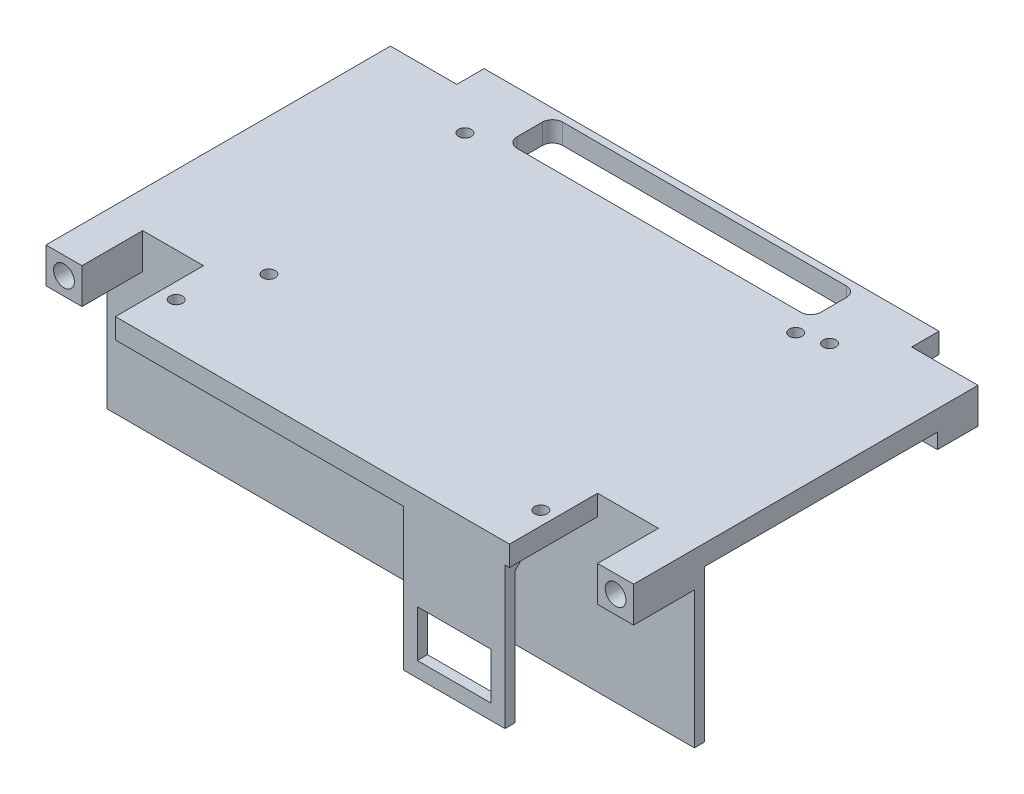
from build123d import *

# Parameters (mm, degrees)
BOSS_EXTRUDE1_DEPTH             = 4
SKETCH3_W                       = 7.1
SKETCH3_H                       = 8
BOSS_EXTRUDE3_DEPTH             = 3
SKETCH4_R                       = 2.05
CUT_EXTRUDE1_DEPTH              = 7
MIRROR2_COPY_1_SKETCH_W         = 7.1
MIRROR2_COPY_1_SKETCH_H         = 8
MIRROR2_COPY_1_DEPTH            = 3
MIRROR2_COPY_2_SKETCH_R         = 2.05
MIRROR2_COPY_2_DEPTH            = 7
SKETCH5_W                       = 60
SKETCH5_H                       = 9
CUT_EXTRUDE2_DEPTH              = 72.37226352
FILLET1_R                       = 2
SKETCH7_W                       = 101.8
SKETCH7_H                       = 1
CUT_EXTRUDE3_DEPTH              = 72.37226352
SKETCH8_W                       = 116
SKETCH8_H                       = 2
BOSS_EXTRUDE4_DEPTH             = 30
SKETCH9_W                       = 12
SKETCH9_H                       = 18
CUT_EXTRUDE4_DEPTH              = 10
SKETCH10_W                      = 7.1
SKETCH10_H                      = 4
BOSS_EXTRUDE5_DEPTH             = 3
SKETCH12_W                      = 1.5
SKETCH12_H                      = 4
BOSS_EXTRUDE6_DEPTH             = 2
SKETCH13_W                      = 36
SKETCH13_H                      = 2
BOSS_EXTRUDE7_DEPTH             = 30
SKETCH14_W                      = 1.5
SKETCH14_H                      = 4
BOSS_EXTRUDE8_DEPTH             = 1
BOSS_EXTRUDE9_REACH             = 79.055
BOSS_EXTRUDE9_DIRECTION_2_REACH = 79.055
SKETCH16_W                      = 20
SKETCH16_H                      = 28
SKETCH16_W_2                    = 14.6
SKETCH16_H_2                    = 9.2
BOSS_EXTRUDE10_DEPTH            = 2.6
SKETCH17_W                      = 12
SKETCH17_H                      = 18
CUT_EXTRUDE5_DEPTH              = 78.054785705
SKETCH18_W                      = 6
SKETCH18_H                      = 6
CUT_EXTRUDE6_DEPTH              = 79.759380394
SKETCH22_R                      = 1.25
CUT_EXTRUDE7_DEPTH              = 4
SKETCH25_W                      = 6
SKETCH25_H                      = 30
CUT_EXTRUDE11_DEPTH             = 10
SKETCH26_W                      = 5.701552738
SKETCH26_H                      = 30.562488548
SKETCH26_W_2                    = 6.53419365
SKETCH26_H_2                    = 28.524331859
CUT_EXTRUDE12_DEPTH             = 78.810282097
CUT_EXTRUDE12_DEPTH_BACK        = 78.810282097
SKETCH27_R                      = 1.25
CUT_EXTRUDE13_DEPTH             = 79.230428862
SKETCH28_W                      = 89.8
SKETCH28_H                      = 0.6
SKETCH28_W_2                    = 77.8
CUT_EXTRUDE14_DEPTH             = 79.230428862
CHAMFER1_SIZE                   = 2


with BuildPart() as part:
    # Sketch1 → Boss-Extrude1 (new body)
    with BuildSketch(Plane(origin=(0, 0, 0), x_dir=(1, 0, 0), z_dir=(0, 1, 0))):
        Polygon((-58, -34), (-50.9, -34), (-50.9, -41), (50.9, -41), (50.9, -34), (58, -34), (58, 34), (50.9, 34), (50.9, 41), (-50.9, 41), (-50.9, 34), (-58, 34), align=None)
    extrude(amount=BOSS_EXTRUDE1_DEPTH)

    # Sketch3 → Boss-Extrude3 (add)
    with BuildSketch(Plane.XZ):
        with Locations((-54.45, -30)):
            Rectangle(SKETCH3_W, SKETCH3_H)
    boss_extrude3 = extrude(amount=BOSS_EXTRUDE3_DEPTH)

    # Sketch4 → Cut-Extrude1 (cut)
    with BuildSketch(Plane(origin=(0, 0, -34), x_dir=(-1, 0, 0), z_dir=(0, 0, -1))):
        with Locations((54.45, 0.5)):
            Circle(SKETCH4_R)
    cut_extrude1 = extrude(amount=-CUT_EXTRUDE1_DEPTH, mode=Mode.SUBTRACT)

    # Mirror1: Boss-Extrude3, Cut-Extrude1 across plane
    add(boss_extrude3.mirror(Plane(origin=(0, 0, 0), x_dir=(0, 0, 1), z_dir=(1, 0, 0))))
    add(cut_extrude1.mirror(Plane(origin=(0, 0, 0), x_dir=(0, 0, 1), z_dir=(1, 0, 0))), mode=Mode.SUBTRACT)

    # Mirror2: Boss-Extrude3, Cut-Extrude1 across plane
    add(boss_extrude3.mirror(Plane.XY))
    add(cut_extrude1.mirror(Plane.XY), mode=Mode.SUBTRACT)

    # Mirror2 copy 1 sketch → Mirror2 copy 1 (add)
    with BuildSketch(Plane(origin=(0, 0, 0), x_dir=(-1, 0, 0), z_dir=(0, -1, 0))):
        with Locations((-54.45, -30)):
            Rectangle(MIRROR2_COPY_1_SKETCH_W, MIRROR2_COPY_1_SKETCH_H)
    extrude(amount=MIRROR2_COPY_1_DEPTH)

    # Mirror2 copy 2 sketch → Mirror2 copy 2 (cut)
    with BuildSketch(Plane.XY.offset(34)):
        with Locations((54.45, 0.5)):
            Circle(MIRROR2_COPY_2_SKETCH_R)
    extrude(amount=-MIRROR2_COPY_2_DEPTH, mode=Mode.SUBTRACT)

    # Sketch5 → Cut-Extrude2 (cut, through all)
    with BuildSketch(Plane(origin=(0, 4, 0), x_dir=(1, 0, 0), z_dir=(0, 1, 0))):
        with Locations((0, 33.5)):
            Rectangle(SKETCH5_W, SKETCH5_H)
    extrude(amount=-CUT_EXTRUDE2_DEPTH, mode=Mode.SUBTRACT)

    # Fillet1
    fillet1_edges = [part.edges().sort_by_distance(p)[0] for p in [
        (-30, 2, -29),
        (-30, 2, -38),
        (30, 2, -38),
        (30, 2, -29),
    ]]
    fillet(fillet1_edges, radius=FILLET1_R)

    # Sketch7 → Cut-Extrude3 (cut, through all)
    with BuildSketch(Plane(origin=(0, 4, 0), x_dir=(1, 0, 0), z_dir=(0, 1, 0))):
        with Locations((0, 40.5)):
            Rectangle(SKETCH7_W, SKETCH7_H)
        with Locations((0, -40.5)):
            Rectangle(SKETCH7_W, SKETCH7_H)
    extrude(amount=-CUT_EXTRUDE3_DEPTH, mode=Mode.SUBTRACT)

    # Sketch8 → Boss-Extrude4 (add)
    with BuildSketch(Plane.XZ):
        with Locations((0, 21)):
            Rectangle(SKETCH8_W, SKETCH8_H)
    extrude(amount=BOSS_EXTRUDE4_DEPTH)

    # Sketch9 → Cut-Extrude4 (cut)
    with BuildSketch(Plane(origin=(0, 4, 0), x_dir=(1, 0, 0), z_dir=(0, 1, 0))):
        with Locations((-44.9, -31)):
            Rectangle(SKETCH9_W, SKETCH9_H)
    extrude(amount=-CUT_EXTRUDE4_DEPTH, mode=Mode.SUBTRACT)

    # Sketch10 → Boss-Extrude5 (add)
    with BuildSketch(Plane.XZ.offset(3)):
        with Locations((-54.45, 24)):
            Rectangle(SKETCH10_W, SKETCH10_H)
        with Locations((54.45, 24)):
            Rectangle(SKETCH10_W, SKETCH10_H)
    extrude(amount=-BOSS_EXTRUDE5_DEPTH)

    # Sketch12 → Boss-Extrude6 (add)
    with BuildSketch(Plane.ZY.offset(51)):
        Polygon((22, -5.8), (22, -16.2), (24.7, -13.5), (24.7, -8.5), align=None)
        with Locations((23.35, -11)):
            Rectangle(SKETCH12_W, SKETCH12_H, mode=Mode.SUBTRACT)
        Polygon((22, -20.8), (22, -31.2), (24.7, -28.5), (24.7, -23.5), align=None)
        with Locations((23.35, -26)):
            Rectangle(SKETCH12_W, SKETCH12_H, mode=Mode.SUBTRACT)
    boss_extrude6 = extrude(amount=-BOSS_EXTRUDE6_DEPTH)

    # Mirror3: Boss-Extrude6 across plane
    add(boss_extrude6.mirror(Plane(origin=(-44.9, 0, 0), x_dir=(0, 0, 1), z_dir=(1, 0, 0))))

    # Sketch13 → Boss-Extrude7 (add)
    with BuildSketch(Plane.XZ):
        with Locations((0, -20.5)):
            Rectangle(SKETCH13_W, SKETCH13_H)
    extrude(amount=BOSS_EXTRUDE7_DEPTH)

    # Sketch14 → Boss-Extrude8 (add, symmetric)
    with BuildSketch(Plane(origin=(0, 0, 0), x_dir=(0, 0, -1), z_dir=(1, 0, 0))):
        Polygon((24.2, -8.5), (21.5, -5.8), (21.5, -16.2), (24.2, -13.5), align=None)
        with Locations((22.85, -11)):
            Rectangle(SKETCH14_W, SKETCH14_H, mode=Mode.SUBTRACT)
    extrude(amount=BOSS_EXTRUDE8_DEPTH, both=True)

    # Boss-Extrude9: up to this face of the body (flat: up to its plane)
    boss_extrude9_end = Plane(part.part.faces().sort_by_distance((-18, -15, -20.5))[0])
    # Sketch15 → Boss-Extrude9 (add, up to the picked face)
    with BuildSketch(Plane(origin=(0, 0, 0), x_dir=(0, 0, -1), z_dir=(1, 0, 0)), mode=Mode.PRIVATE) as boss_extrude9_sk1:
        Polygon((19.5, 0), (19.5, -5), (16.613248654, 0), align=None)
    boss_extrude9_tool1 = split(extrude(boss_extrude9_sk1.sketch, amount=-BOSS_EXTRUDE9_REACH, mode=Mode.PRIVATE), bisect_by=boss_extrude9_end, keep=Keep.BOTH, mode=Mode.PRIVATE)
    add(boss_extrude9_tool1.solids().sort_by(Axis((0, -1.666667, -18.53775), (-1, 0, 0)))[0])

    # Boss-Extrude9 direction 2: up to this face of the body (flat: up to its plane)
    boss_extrude9_direction_2_end = Plane(part.part.faces().sort_by_distance((18, -15, -20.5))[0])
    # Sketch15 → Boss-Extrude9 direction 2 (add, up to the picked face)
    with BuildSketch(Plane(origin=(0, 0, 0), x_dir=(0, 0, -1), z_dir=(1, 0, 0)), mode=Mode.PRIVATE) as boss_extrude9_direction_2_sk1:
        Polygon((19.5, 0), (19.5, -5), (16.613248654, 0), align=None)
    boss_extrude9_direction_2_tool1 = split(extrude(boss_extrude9_direction_2_sk1.sketch, amount=BOSS_EXTRUDE9_DIRECTION_2_REACH, mode=Mode.PRIVATE), bisect_by=boss_extrude9_direction_2_end, keep=Keep.BOTH, mode=Mode.PRIVATE)
    add(boss_extrude9_direction_2_tool1.solids().sort_by(Axis((0, -1.666667, -18.53775), (1, 0, 0)))[0])

    # Sketch16 → Boss-Extrude10 (add)
    with BuildSketch(Plane.XY.offset(40)):
        with Locations((28, -14)):
            Rectangle(SKETCH16_W, SKETCH16_H)
        with Locations((28, -20.4)):
            Rectangle(SKETCH16_W_2, SKETCH16_H_2, mode=Mode.SUBTRACT)
    extrude(amount=-BOSS_EXTRUDE10_DEPTH)

    # Sketch17 → Cut-Extrude5 (cut, through all)
    with BuildSketch(Plane.XZ):
        with Locations((44.9, 31)):
            Rectangle(SKETCH17_W, SKETCH17_H)
    extrude(amount=-CUT_EXTRUDE5_DEPTH, mode=Mode.SUBTRACT)

    # Sketch18 → Cut-Extrude6 (cut, through all)
    with BuildSketch(Plane(origin=(0, 4, 0), x_dir=(1, 0, 0), z_dir=(0, 1, 0))):
        with Locations((47.9, 37)):
            Rectangle(SKETCH18_W, SKETCH18_H)
        with Locations((-47.9, 37)):
            Rectangle(SKETCH18_W, SKETCH18_H)
    extrude(amount=-CUT_EXTRUDE6_DEPTH, mode=Mode.SUBTRACT)

    # Sketch22 → Cut-Extrude7 (cut)
    with BuildSketch(Plane(origin=(0, 4, 0), x_dir=(1, 0, 0), z_dir=(0, 1, 0))):
        with Locations(Location((31, 25, 0), (0, 0, 270))):
            Circle(SKETCH22_R)
        with Locations(Location((-31, -17, 0), (0, 0, 270))):
            Circle(SKETCH22_R)
    extrude(amount=-CUT_EXTRUDE7_DEPTH, mode=Mode.SUBTRACT)

    # Sketch25 → Cut-Extrude11 (cut)
    with BuildSketch(Plane(origin=(0, 0, -21.5), x_dir=(-1, 0, 0), z_dir=(0, 0, -1))):
        with Locations((-15, -15)):
            Rectangle(SKETCH25_W, SKETCH25_H)
        with Locations((15, -15)):
            Rectangle(SKETCH25_W, SKETCH25_H)
    extrude(amount=-CUT_EXTRUDE11_DEPTH, mode=Mode.SUBTRACT)

    # Sketch26 → Cut-Extrude12 (cut, two sides)
    with BuildSketch(Plane.ZY.offset(1)) as cut_extrude12_sk:
        with Locations((-24.350776369, -21.081244274)):
            Rectangle(SKETCH26_W, SKETCH26_H)
        with Locations((25.267096825, -20.06216593)):
            Rectangle(SKETCH26_W_2, SKETCH26_H_2)
    extrude(amount=CUT_EXTRUDE12_DEPTH, mode=Mode.SUBTRACT)
    extrude(cut_extrude12_sk.sketch, amount=-CUT_EXTRUDE12_DEPTH_BACK, mode=Mode.SUBTRACT)

    # Sketch27 → Cut-Extrude13 (cut, through all)
    with BuildSketch(Plane(origin=(0, 4, 0), x_dir=(1, 0, 0), z_dir=(0, 1, 0))):
        with Locations(Location((-35.8, 26.5, 0), (0, 0, 270))):
            Circle(SKETCH27_R)
        with Locations(Location((-35.8, -30.5, 0), (0, 0, 270))):
            Circle(SKETCH27_R)
        with Locations(Location((36.2, -30.5, 0), (0, 0, 270))):
            Circle(SKETCH27_R)
        with Locations(Location((36.2, 26.5, 0), (0, 0, 270))):
            Circle(SKETCH27_R)
    extrude(amount=-CUT_EXTRUDE13_DEPTH, mode=Mode.SUBTRACT)

    # Sketch28 → Cut-Extrude14 (cut, through all)
    with BuildSketch(Plane(origin=(0, 4, 0), x_dir=(1, 0, 0), z_dir=(0, 1, 0))):
        with Locations((0, 39.7)):
            Rectangle(SKETCH28_W, SKETCH28_H)
        with Locations((0, -39.7)):
            Rectangle(SKETCH28_W_2, SKETCH28_H)
    extrude(amount=-CUT_EXTRUDE14_DEPTH, mode=Mode.SUBTRACT)

    # Chamfer1
    chamfer1_edges = [part.edges().sort_by_distance(p)[0] for p in [
        (28, 0, 37.4),
    ]]
    chamfer(chamfer1_edges, length=CHAMFER1_SIZE)


solid = part.part
